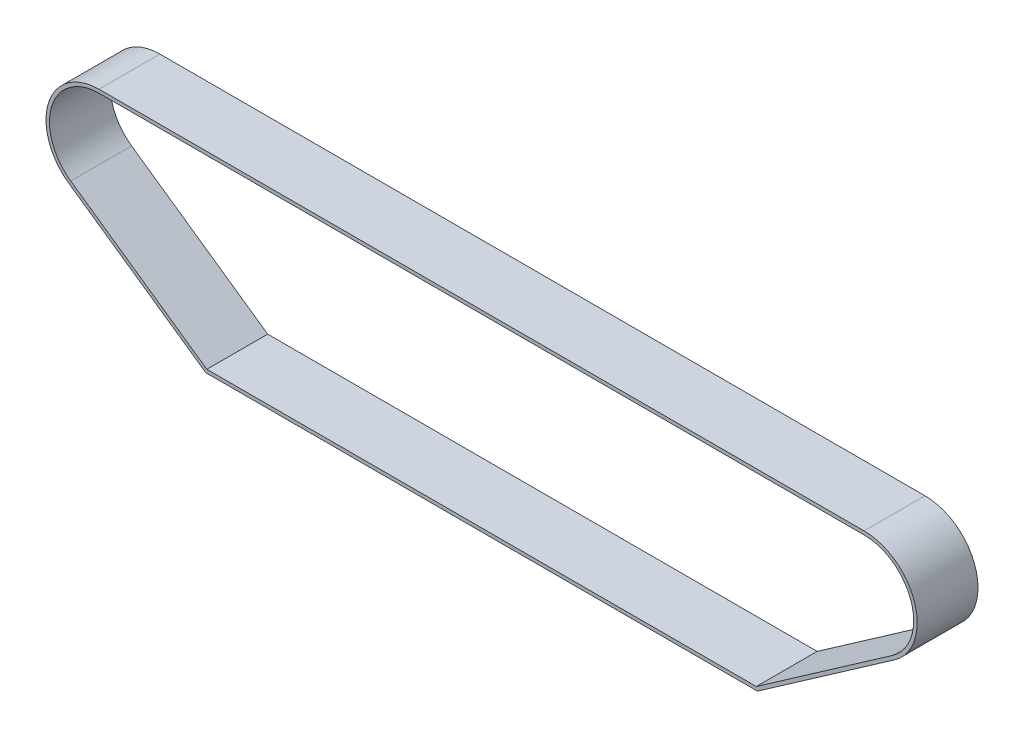
from build123d import *

# Parameters (mm, degrees)
EXTRUDE_1_DEPTH = 35


with BuildPart() as part:
    # 草图1 → 拉伸-薄壁1 (new body)
    with BuildSketch(Plane.XY):
        with BuildLine():
            Line((237.450135309, -25.014851143), (158.628665481, -80))
            Line((158.628665481, -80), (-158.628665481, -80))
            Line((-158.628665481, -80), (-237.450135309, -25.014851143))
            ThreePointArc((-237.450135309, -25.014851143), (-249.09641696, 9.145956487), (-220, 30.5))
            Line((-220, 30.5), (220, 30.5))
            ThreePointArc((220, 30.5), (249.09641696, 9.145956487), (237.450135309, -25.014851143))
        make_face()
        with BuildLine():
            Line((236.305864141, -23.374533035), (158, -78))
            Line((158, -78), (-158, -78))
            Line((-158, -78), (-236.305864141, -23.374533035))
            ThreePointArc((-236.305864141, -23.374533035), (-247.188455192, 8.546221636), (-220, 28.5))
            Line((-220, 28.5), (220, 28.5))
            ThreePointArc((220, 28.5), (247.188455192, 8.546221636), (236.305864141, -23.374533035))
        make_face(mode=Mode.SUBTRACT)
    extrude(amount=EXTRUDE_1_DEPTH)


solid = part.part
